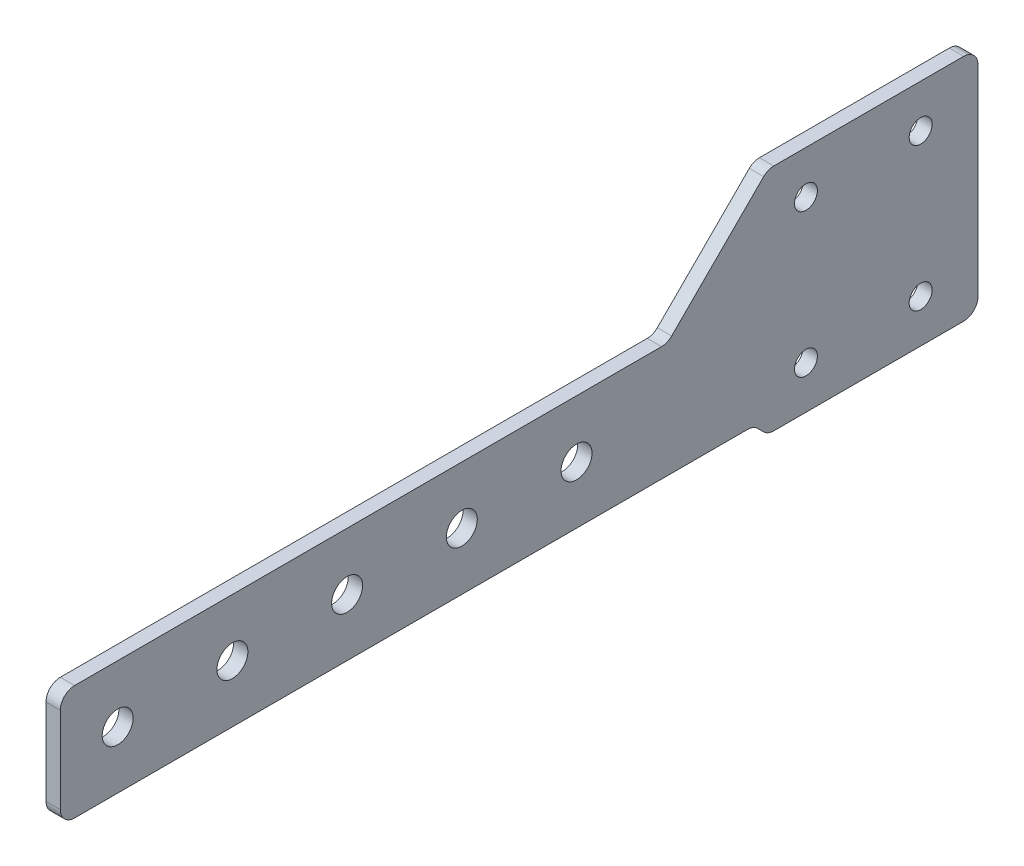
from build123d import *

# Parameters (mm, degrees)
SKETCH2_R           = 3.429
SKETCH2_R_2         = 2.54
BOSS_EXTRUDE1_DEPTH = 3.175


with BuildPart() as part:
    # Sketch2 → Boss-Extrude1 (new body)
    with BuildSketch(Plane(origin=(0, 0, 0), x_dir=(0, 0, -1), z_dir=(1, 0, 0))):
        with BuildLine():
            Line((-111.125, 12.7), (18.824359697, 12.7))
            ThreePointArc((18.824359697, 12.7), (20.039379595, 12.941682484), (21.069423728, 13.62993597))
            Line((21.069423728, 13.62993597), (41.434551788, 33.99506403))
            ThreePointArc((41.434551788, 33.99506403), (42.464595921, 34.683317516), (43.679615818, 34.925))
            Line((43.679615818, 34.925), (85.725, 34.925))
            ThreePointArc((85.725, 34.925), (87.97006403, 33.99506403), (88.9, 31.75))
            Line((88.9, 31.75), (88.9, -12.7))
            ThreePointArc((88.9, -12.7), (87.97006403, -14.94506403), (85.725, -15.875))
            Line((85.725, -15.875), (43.679615818, -15.875))
            ThreePointArc((43.679615818, -15.875), (42.464595921, -15.633317516), (41.434551788, -14.94506403))
            Line((41.434551788, -14.94506403), (40.119423728, -13.62993597))
            ThreePointArc((40.119423728, -13.62993597), (39.089379595, -12.941682484), (37.874359697, -12.7))
            Line((37.874359697, -12.7), (-111.125, -12.7))
            ThreePointArc((-111.125, -12.7), (-113.37006403, -11.77006403), (-114.3, -9.525))
            Line((-114.3, -9.525), (-114.3, 9.525))
            ThreePointArc((-114.3, 9.525), (-113.37006403, 11.77006403), (-111.125, 12.7))
        make_face()
        with Locations((-101.6, 0)):
            Circle(SKETCH2_R, mode=Mode.SUBTRACT)
        with Locations((-76.2, 0)):
            Circle(SKETCH2_R, mode=Mode.SUBTRACT)
        with Locations((-50.8, 0)):
            Circle(SKETCH2_R, mode=Mode.SUBTRACT)
        with Locations((-25.4, 0)):
            Circle(SKETCH2_R, mode=Mode.SUBTRACT)
        Circle(SKETCH2_R, mode=Mode.SUBTRACT)
        with Locations((50.8, 25.4)):
            Circle(SKETCH2_R_2, mode=Mode.SUBTRACT)
        with Locations((76.2, 25.4)):
            Circle(SKETCH2_R_2, mode=Mode.SUBTRACT)
        with Locations((50.8, -6.35)):
            Circle(SKETCH2_R_2, mode=Mode.SUBTRACT)
        with Locations((76.2, -6.35)):
            Circle(SKETCH2_R_2, mode=Mode.SUBTRACT)
    extrude(amount=BOSS_EXTRUDE1_DEPTH)


solid = part.part
